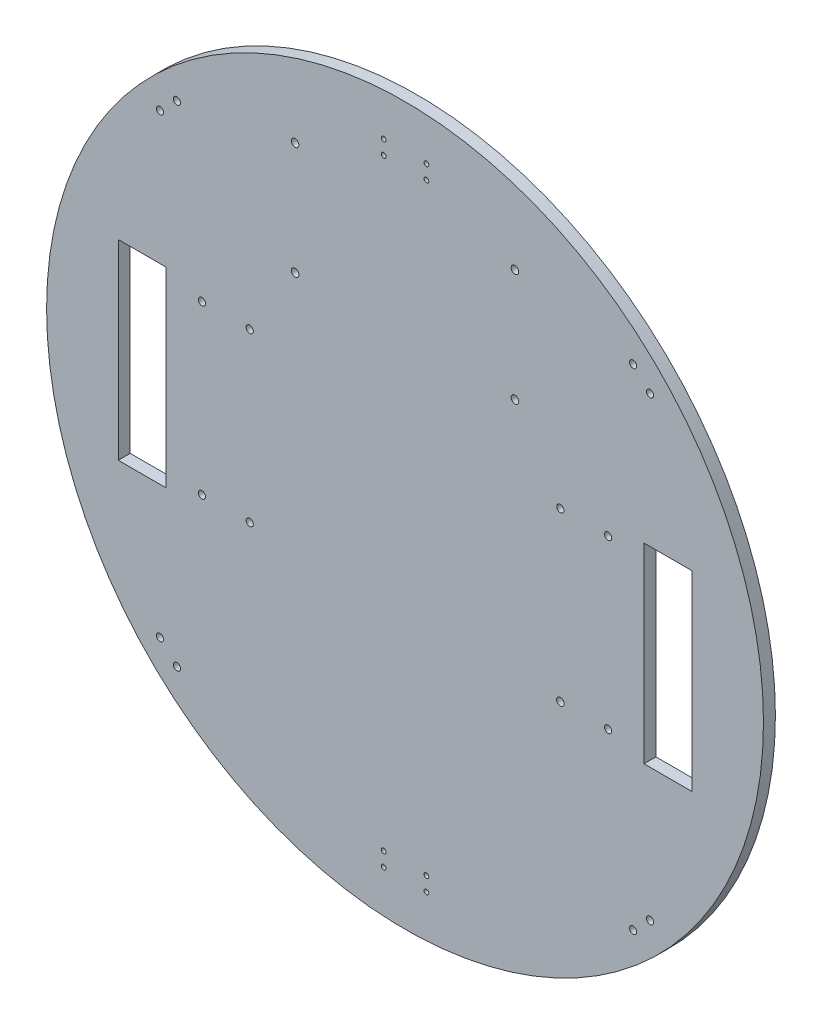
from build123d import *

# Parameters (mm, degrees)
ESQUISSE1_R                         = 150
BASE_CIRCULAIRE_DEPTH               = 5
ESQUISSE2_W                         = 20
ESQUISSE2_H                         = 80
EMPLACEMENT_ROUES_DEPTH             = 6
ESQUISSE3_R                         = 1.5
ESQUISSE3_R_2                       = 1.575487657
TROUS_FIXATION_MORS_DEPTH           = 6
ESQUISSE4_R                         = 1.5
TROUS_FIXATION_PAROIS_DEPTH         = 6
ESQUISSE5_R                         = 1
TROUS_FIXATION_ROUES_FOLLES_DEPTH   = 6
ESQUISSE6_R                         = 1.59
TROUS_FIXATION_CARTE_OPEN_UPS_DEPTH = 6


with BuildPart() as part:
    # Esquisse1 → base_circulaire (new body)
    with BuildSketch(Plane.XY):
        Circle(ESQUISSE1_R)
    extrude(amount=BASE_CIRCULAIRE_DEPTH)

    # Esquisse2 → emplacement_roues (cut, through all)
    with BuildSketch(Plane.XY.offset(5)):
        with Locations((-110, 0)):
            Rectangle(ESQUISSE2_W, ESQUISSE2_H)
        with Locations((110, 0)):
            Rectangle(ESQUISSE2_W, ESQUISSE2_H)
    extrude(amount=-EMPLACEMENT_ROUES_DEPTH, mode=Mode.SUBTRACT)

    # Esquisse3 → trous_fixation_mors (cut, through all)
    with BuildSketch(Plane.XY.offset(5)):
        with Locations((-85, 35)):
            Circle(ESQUISSE3_R)
        with Locations((-85, -35)):
            Circle(ESQUISSE3_R)
        with Locations((85, 35)):
            Circle(ESQUISSE3_R)
        with Locations((85, -35)):
            Circle(ESQUISSE3_R)
        with Locations((65, -35)):
            Circle(ESQUISSE3_R_2)
        with Locations((65, 35)):
            Circle(ESQUISSE3_R)
        with Locations((-65, -35)):
            Circle(ESQUISSE3_R)
        with Locations((-65, 35)):
            Circle(ESQUISSE3_R)
    extrude(amount=-TROUS_FIXATION_MORS_DEPTH, mode=Mode.SUBTRACT)

    # Esquisse4 → trous fixation parois (cut, through all)
    with BuildSketch(Plane.XY.offset(5)):
        with Locations((-102.530483272, 95.45941546)):
            Circle(ESQUISSE4_R)
        with Locations((-95.45941546, 102.530483272)):
            Circle(ESQUISSE4_R)
        with Locations((95.45941546, 102.530483272)):
            Circle(ESQUISSE4_R)
        with Locations((102.530483272, 95.45941546)):
            Circle(ESQUISSE4_R)
        with Locations((102.530483272, -95.45941546)):
            Circle(ESQUISSE4_R)
        with Locations((95.45941546, -102.530483272)):
            Circle(ESQUISSE4_R)
        with Locations((-95.45941546, -102.530483272)):
            Circle(ESQUISSE4_R)
        with Locations((-102.530483272, -95.45941546)):
            Circle(ESQUISSE4_R)
    extrude(amount=-TROUS_FIXATION_PAROIS_DEPTH, mode=Mode.SUBTRACT)

    # Esquisse5 → trous fixation roues folles (cut, through all)
    with BuildSketch(Plane.XY.offset(5)):
        with Locations((8.947, 126.053)):
            Circle(ESQUISSE5_R)
        with Locations((8.947, 131.947)):
            Circle(ESQUISSE5_R)
        with Locations((-8.947, 126.053)):
            Circle(ESQUISSE5_R)
        with Locations((-8.947, 131.947)):
            Circle(ESQUISSE5_R)
        with Locations((8.947, -131.947)):
            Circle(ESQUISSE5_R)
        with Locations((-8.947, -131.947)):
            Circle(ESQUISSE5_R)
        with Locations((8.947, -126.053)):
            Circle(ESQUISSE5_R)
        with Locations((-8.947, -126.053)):
            Circle(ESQUISSE5_R)
    extrude(amount=-TROUS_FIXATION_ROUES_FOLLES_DEPTH, mode=Mode.SUBTRACT)

    # Esquisse6 → trous fixation carte open UPS (cut, through all)
    with BuildSketch(Plane.XY.offset(5)):
        with Locations((46.005, 65)):
            Circle(ESQUISSE6_R)
        with Locations((46.005, 112.01)):
            Circle(ESQUISSE6_R)
        with Locations((-46.005, 65)):
            Circle(ESQUISSE6_R)
        with Locations((-46.005, 112.01)):
            Circle(ESQUISSE6_R)
    extrude(amount=-TROUS_FIXATION_CARTE_OPEN_UPS_DEPTH, mode=Mode.SUBTRACT)


solid = part.part
